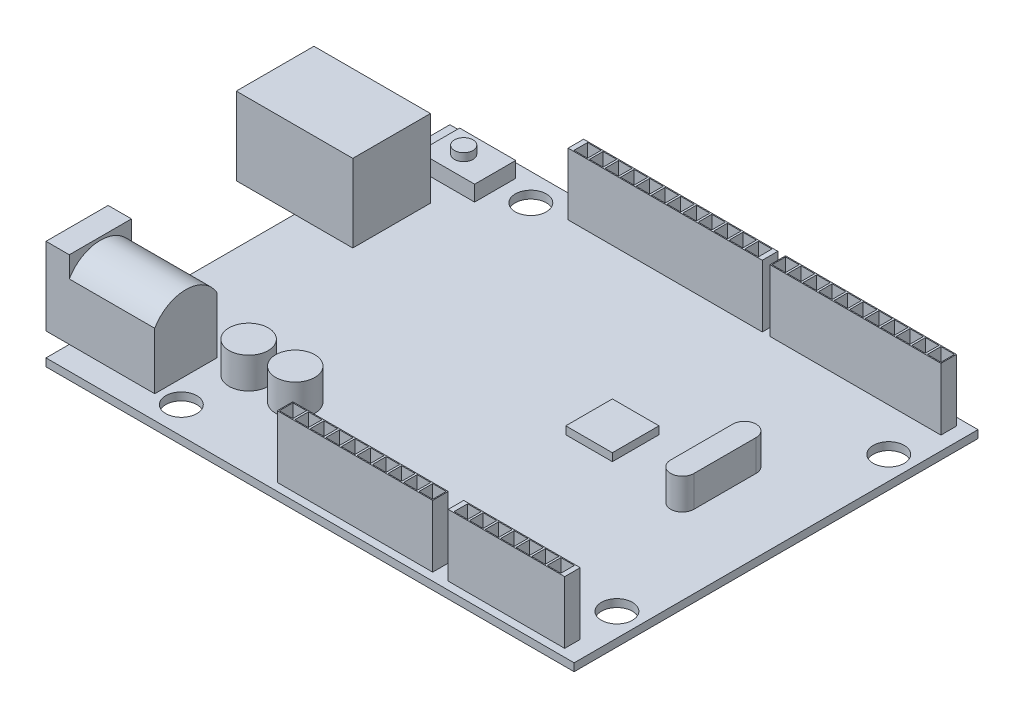
from build123d import *

# Parameters (mm, degrees)
SKETCH1_W            = 68
SKETCH1_H            = 52
BOSS_EXTRUDE1_DEPTH  = 1
SKETCH2_W            = 15
SKETCH2_H            = 10
BOSS_EXTRUDE2_DEPTH  = 10
CUT_EXTRUDE1_DEPTH   = 12
SKETCH4_W            = 6
SKETCH4_H            = 3
BOSS_EXTRUDE3_DEPTH  = 12
SKETCH5_W            = 14
SKETCH5_H            = 8
BOSS_EXTRUDE4_DEPTH  = 10
CUT_EXTRUDE3_DEPTH   = 11
SKETCH8_R            = 3
CUT_EXTRUDE4_DEPTH   = 10
SKETCH9_R            = 0.5
BOSS_EXTRUDE5_DEPTH  = 10
SKETCH10_W           = 7.223429862
SKETCH10_H           = 5.297181898
BOSS_EXTRUDE6_DEPTH  = 2
SKETCH11_R           = 1.19217919
BOSS_EXTRUDE7_DEPTH  = 1
SKETCH12_R           = 2.528200452
BOSS_EXTRUDE8_DEPTH  = 4
SKETCH13_W           = 25
SKETCH13_H           = 2
SKETCH13_W_2         = 22
BOSS_EXTRUDE9_DEPTH  = 8
SKETCH14_W           = 15
SKETCH14_H           = 2
SKETCH14_W_2         = 20
BOSS_EXTRUDE10_DEPTH = 8
SKETCH15_W           = 1.75
SKETCH15_H           = 1.75
CUT_EXTRUDE5_DEPTH   = 7
SKETCH16_W           = 1.75
SKETCH16_H           = 1.75
CUT_EXTRUDE6_DEPTH   = 7
SKETCH17_W           = 1.75
SKETCH17_H           = 1.75
CUT_EXTRUDE7_DEPTH   = 7
SKETCH18_W           = 1.75
SKETCH18_H           = 1.75
CUT_EXTRUDE8_DEPTH   = 7
BOSS_EXTRUDE11_DEPTH = 4
SKETCH20_W           = 6
SKETCH20_H           = 6
BOSS_EXTRUDE12_DEPTH = 1
SKETCH21_R           = 2
CUT_EXTRUDE9_DEPTH   = 2


with BuildPart() as part:
    # Sketch1 → Boss-Extrude1 (new body)
    with BuildSketch(Plane(origin=(0, 0, 0), x_dir=(1, 0, 0), z_dir=(0, 1, 0))):
        Rectangle(SKETCH1_W, SKETCH1_H)
    extrude(amount=BOSS_EXTRUDE1_DEPTH)

    # Sketch2 → Boss-Extrude2 (add)
    with BuildSketch(Plane(origin=(0, 1, 0), x_dir=(1, 0, 0), z_dir=(0, 1, 0))):
        with Locations((-34, 11)):
            Rectangle(SKETCH2_W, SKETCH2_H)
    extrude(amount=BOSS_EXTRUDE2_DEPTH)

    # Sketch3 → Cut-Extrude1 (cut)
    with BuildSketch(Plane.ZY.offset(41.5)):
        Polygon((-15, 1.67137748), (-7, 1.67137748), (-7, 9.32862252), (-8, 10.32862252), (-14, 10.32862252), (-15, 9.32862252), align=None)
    extrude(amount=-CUT_EXTRUDE1_DEPTH, mode=Mode.SUBTRACT)

    # Sketch4 → Boss-Extrude3 (add)
    with BuildSketch(Plane.ZY.offset(29.5)):
        with Locations((-11, 5.5)):
            Rectangle(SKETCH4_W, SKETCH4_H)
    extrude(amount=BOSS_EXTRUDE3_DEPTH)

    # Sketch5 → Boss-Extrude4 (add)
    with BuildSketch(Plane(origin=(0, 1, 0), x_dir=(1, 0, 0), z_dir=(0, 1, 0))):
        with Locations((-30, -19)):
            Rectangle(SKETCH5_W, SKETCH5_H)
    extrude(amount=BOSS_EXTRUDE4_DEPTH)

    # Sketch7 → Cut-Extrude3 (cut)
    with BuildSketch(Plane(origin=(-23, 0, 0), x_dir=(0, 0, -1), z_dir=(1, 0, 0))):
        with BuildLine():
            Line((-23.015724783, 8.273244103), (-27.545004123, 8.273244103))
            Line((-27.545004123, 8.273244103), (-27.545004123, 16.320616208))
            Line((-27.545004123, 16.320616208), (-10.311736267, 16.320616208))
            Line((-10.311736267, 16.320616208), (-10.311736267, 8.273244103))
            Line((-10.311736267, 8.273244103), (-14.984275217, 8.273244103))
            ThreePointArc((-14.984275217, 8.273244103), (-19, 10.614508021), (-23.015724783, 8.273244103))
        make_face()
    extrude(amount=-CUT_EXTRUDE3_DEPTH, mode=Mode.SUBTRACT)

    # Sketch8 → Cut-Extrude4 (cut)
    with BuildSketch(Plane.ZY.offset(37)):
        with Locations((19, 6)):
            Circle(SKETCH8_R)
    extrude(amount=-CUT_EXTRUDE4_DEPTH, mode=Mode.SUBTRACT)

    # Sketch9 → Boss-Extrude5 (add)
    with BuildSketch(Plane.ZY.offset(27)):
        with Locations((19, 6)):
            Circle(SKETCH9_R)
    extrude(amount=BOSS_EXTRUDE5_DEPTH)

    # Sketch10 → Boss-Extrude6 (add)
    with BuildSketch(Plane(origin=(0, 1, 0), x_dir=(1, 0, 0), z_dir=(0, 1, 0))):
        with Locations((-27.388285069, 21.610094337)):
            Rectangle(SKETCH10_W, SKETCH10_H)
    extrude(amount=BOSS_EXTRUDE6_DEPTH)

    # Sketch11 → Boss-Extrude7 (add)
    with BuildSketch(Plane(origin=(0, 3, 0), x_dir=(1, 0, 0), z_dir=(0, 1, 0))):
        with Locations((-27.82809954, 21.610094337)):
            Circle(SKETCH11_R)
    extrude(amount=BOSS_EXTRUDE7_DEPTH)

    # Sketch12 → Boss-Extrude8 (add)
    with BuildSketch(Plane(origin=(0, 1, 0), x_dir=(1, 0, 0), z_dir=(0, 1, 0))):
        with Locations((-19.039593208, -14.868226466)):
            Circle(SKETCH12_R)
        with Locations((-13.039593208, -14.868226466)):
            Circle(SKETCH12_R)
    extrude(amount=BOSS_EXTRUDE8_DEPTH)

    # Sketch13 → Boss-Extrude9 (add)
    with BuildSketch(Plane(origin=(0, 1, 0), x_dir=(1, 0, 0), z_dir=(0, 1, 0))):
        with Locations((-3.276570138, 24)):
            Rectangle(SKETCH13_W, SKETCH13_H)
        with Locations((21.223429862, 24)):
            Rectangle(SKETCH13_W_2, SKETCH13_H)
    extrude(amount=BOSS_EXTRUDE9_DEPTH)

    # Sketch14 → Boss-Extrude10 (add)
    with BuildSketch(Plane(origin=(0, 1, 0), x_dir=(1, 0, 0), z_dir=(0, 1, 0))):
        with Locations((24.283615391, -24)):
            Rectangle(SKETCH14_W, SKETCH14_H)
        with Locations((4.783615391, -24)):
            Rectangle(SKETCH14_W_2, SKETCH14_H)
    extrude(amount=BOSS_EXTRUDE10_DEPTH)

    # Sketch15 → Cut-Extrude5 (cut)
    with BuildSketch(Plane(origin=(0, 9, 0), x_dir=(1, 0, 0), z_dir=(0, 1, 0))):
        with Locations((-14.276570138, 24)):
            Rectangle(SKETCH15_W, SKETCH15_H)
        with Locations((-12.276570138, 24)):
            Rectangle(SKETCH15_W, SKETCH15_H)
        with Locations((-10.276570138, 24)):
            Rectangle(SKETCH15_W, SKETCH15_H)
        with Locations((-8.276570138, 24)):
            Rectangle(SKETCH15_W, SKETCH15_H)
        with Locations((-6.276570138, 24)):
            Rectangle(SKETCH15_W, SKETCH15_H)
        with Locations((-4.276570138, 24)):
            Rectangle(SKETCH15_W, SKETCH15_H)
        with Locations((-2.276570138, 24)):
            Rectangle(SKETCH15_W, SKETCH15_H)
        with Locations((-0.276570138, 24)):
            Rectangle(SKETCH15_W, SKETCH15_H)
        with Locations((1.723429862, 24)):
            Rectangle(SKETCH15_W, SKETCH15_H)
        with Locations((3.723429862, 24)):
            Rectangle(SKETCH15_W, SKETCH15_H)
        with Locations((5.723429862, 24)):
            Rectangle(SKETCH15_W, SKETCH15_H)
        with Locations((7.723429862, 24)):
            Rectangle(SKETCH15_W, SKETCH15_H)
    extrude(amount=-CUT_EXTRUDE5_DEPTH, mode=Mode.SUBTRACT)

    # Sketch16 → Cut-Extrude6 (cut)
    with BuildSketch(Plane(origin=(0, 9, 0), x_dir=(1, 0, 0), z_dir=(0, 1, 0))):
        with Locations((11.223429862, 24)):
            Rectangle(SKETCH16_W, SKETCH16_H)
        with Locations((13.223429862, 24)):
            Rectangle(SKETCH16_W, SKETCH16_H)
        with Locations((15.223429862, 24)):
            Rectangle(SKETCH16_W, SKETCH16_H)
        with Locations((17.223429862, 24)):
            Rectangle(SKETCH16_W, SKETCH16_H)
        with Locations((19.223429862, 24)):
            Rectangle(SKETCH16_W, SKETCH16_H)
        with Locations((21.223429862, 24)):
            Rectangle(SKETCH16_W, SKETCH16_H)
        with Locations((23.223429862, 24)):
            Rectangle(SKETCH16_W, SKETCH16_H)
        with Locations((25.223429862, 24)):
            Rectangle(SKETCH16_W, SKETCH16_H)
        with Locations((27.223429862, 24)):
            Rectangle(SKETCH16_W, SKETCH16_H)
        with Locations((29.223429862, 24)):
            Rectangle(SKETCH16_W, SKETCH16_H)
        with Locations((31.223429862, 24)):
            Rectangle(SKETCH16_W, SKETCH16_H)
    extrude(amount=-CUT_EXTRUDE6_DEPTH, mode=Mode.SUBTRACT)

    # Sketch17 → Cut-Extrude7 (cut)
    with BuildSketch(Plane(origin=(0, 9, 0), x_dir=(1, 0, 0), z_dir=(0, 1, 0))):
        with Locations((-4.216384609, -24)):
            Rectangle(SKETCH17_W, SKETCH17_H)
        with Locations((-2.216384609, -24)):
            Rectangle(SKETCH17_W, SKETCH17_H)
        with Locations((-0.216384609, -24)):
            Rectangle(SKETCH17_W, SKETCH17_H)
        with Locations((1.783615391, -24)):
            Rectangle(SKETCH17_W, SKETCH17_H)
        with Locations((3.783615391, -24)):
            Rectangle(SKETCH17_W, SKETCH17_H)
        with Locations((5.783615391, -24)):
            Rectangle(SKETCH17_W, SKETCH17_H)
        with Locations((7.783615391, -24)):
            Rectangle(SKETCH17_W, SKETCH17_H)
        with Locations((9.783615391, -24)):
            Rectangle(SKETCH17_W, SKETCH17_H)
        with Locations((11.783615391, -24)):
            Rectangle(SKETCH17_W, SKETCH17_H)
        with Locations((13.783615391, -24)):
            Rectangle(SKETCH17_W, SKETCH17_H)
    extrude(amount=-CUT_EXTRUDE7_DEPTH, mode=Mode.SUBTRACT)

    # Sketch18 → Cut-Extrude8 (cut)
    with BuildSketch(Plane(origin=(0, 9, 0), x_dir=(1, 0, 0), z_dir=(0, 1, 0))):
        with Locations((18.283615391, -24)):
            Rectangle(SKETCH18_W, SKETCH18_H)
        with Locations((20.283615391, -24)):
            Rectangle(SKETCH18_W, SKETCH18_H)
        with Locations((22.283615391, -24)):
            Rectangle(SKETCH18_W, SKETCH18_H)
        with Locations((24.283615391, -24)):
            Rectangle(SKETCH18_W, SKETCH18_H)
        with Locations((26.283615391, -24)):
            Rectangle(SKETCH18_W, SKETCH18_H)
        with Locations((28.283615391, -24)):
            Rectangle(SKETCH18_W, SKETCH18_H)
        with Locations((30.283615391, -24)):
            Rectangle(SKETCH18_W, SKETCH18_H)
    extrude(amount=-CUT_EXTRUDE8_DEPTH, mode=Mode.SUBTRACT)

    # Sketch19 → Boss-Extrude11 (add)
    with BuildSketch(Plane(origin=(0, 1, 0), x_dir=(1, 0, 0), z_dir=(0, 1, 0))):
        with BuildLine():
            Line((21.597080987, -1.170823304), (21.597080987, 6.829176696))
            ThreePointArc((21.597080987, 6.829176696), (23.097080987, 8.329176696), (24.597080987, 6.829176696))
            Line((24.597080987, 6.829176696), (24.597080987, -1.170823304))
            ThreePointArc((24.597080987, -1.170823304), (23.097080987, -2.670823304), (21.597080987, -1.170823304))
        make_face()
    extrude(amount=BOSS_EXTRUDE11_DEPTH)

    # Sketch20 → Boss-Extrude12 (add)
    with BuildSketch(Plane(origin=(0, 1, 0), x_dir=(1, 0, 0), z_dir=(0, 1, 0))):
        with Locations((11.035412594, 1.886482859)):
            Rectangle(SKETCH20_W, SKETCH20_H)
    extrude(amount=BOSS_EXTRUDE12_DEPTH)

    # Sketch21 → Cut-Extrude9 (cut, through all)
    with BuildSketch(Plane(origin=(0, 1, 0), x_dir=(1, 0, 0), z_dir=(0, 1, 0))):
        with Locations((-20.075224468, 22.5)):
            Circle(SKETCH21_R)
        with Locations((-20.075224468, -22.5)):
            Circle(SKETCH21_R)
        with Locations((31.01007506, -17.5)):
            Circle(SKETCH21_R)
        with Locations((31.01007506, 17.5)):
            Circle(SKETCH21_R)
    extrude(amount=-CUT_EXTRUDE9_DEPTH, mode=Mode.SUBTRACT)


solid = part.part
